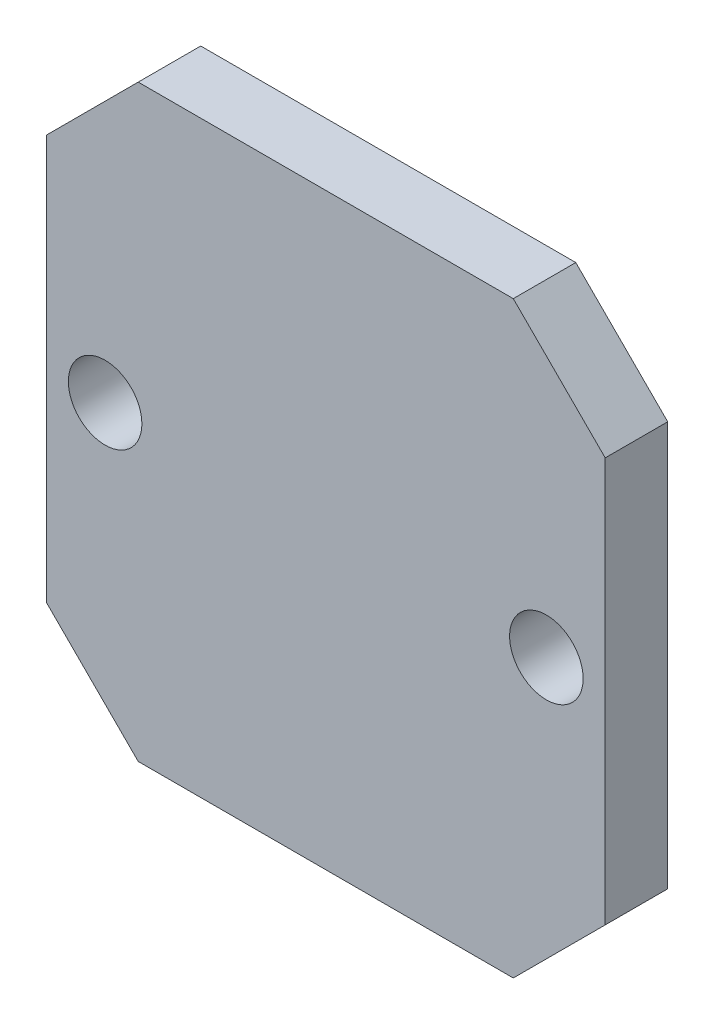
from build123d import *

# Parameters (mm, degrees)
ESQUISSE1_W        = 15.2
ESQUISSE1_H        = 16
ESQUISSE1_R        = 1
BOSS_EXTRU_1_DEPTH = 1.7
CHANFREIN1_SIZE    = 2.5


with BuildPart() as part:
    # Esquisse1 → Boss.-Extru.1 (new body)
    with BuildSketch(Plane.XY):
        Rectangle(ESQUISSE1_W, ESQUISSE1_H)
        with Locations((-6, 0)):
            Circle(ESQUISSE1_R, mode=Mode.SUBTRACT)
        with Locations((6, 0)):
            Circle(ESQUISSE1_R, mode=Mode.SUBTRACT)
    extrude(amount=BOSS_EXTRU_1_DEPTH)

    # Chanfrein1
    chanfrein1_edges = [part.edges().sort_by_distance(p)[0] for p in [
        (-7.6, 8, 0.85),
        (7.6, 8, 0.85),
        (7.6, -8, 0.85),
        (-7.6, -8, 0.85),
    ]]
    chamfer(chanfrein1_edges, length=CHANFREIN1_SIZE)


solid = part.part
